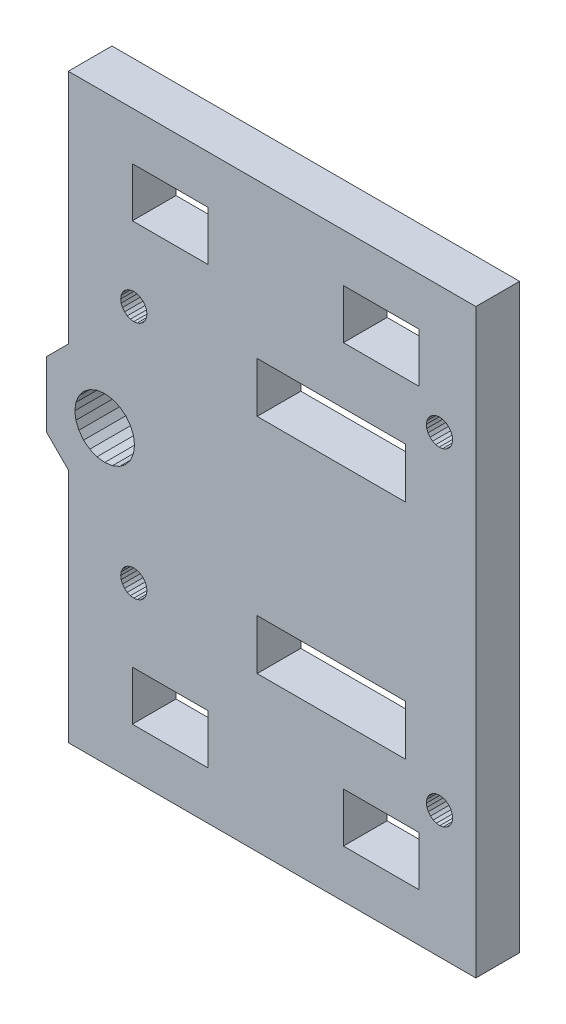
from build123d import *

# Parameters (mm, degrees)
SKETCH1_W           = 20.368459162
SKETCH1_H           = 6.9
SKETCH1_W_2         = 10.4
SKETCH1_H_2         = 6.8
BOSS_EXTRUDE1_DEPTH = 6


with BuildPart() as part:
    # Sketch1 → Boss-Extrude1 (new body)
    with BuildSketch(Plane.XY):
        Polygon((-451.41165464, -88.013150874), (-507.41165464, -88.013150874), (-507.41165464, -120.474064779), (-510.41165464, -123.474064779), (-510.41165464, -132.452236968), (-507.41165464, -135.452236968), (-507.41165464, -167.913150874), (-451.41165464, -167.913150874), align=None)
        with Locations((-471.27842313, -143.263150874)):
            Rectangle(SKETCH1_W, SKETCH1_H, mode=Mode.SUBTRACT)
        Polygon((-498.31165464, -127.963150874), (-498.451358752, -126.901992789), (-498.860950485, -125.913150874), (-499.512516837, -125.064013071), (-500.36165464, -124.412446718), (-501.350496555, -124.002854986), (-502.41165464, -123.863150874), (-503.472812725, -124.002854986), (-504.46165464, -124.412446718), (-505.310792443, -125.064013071), (-505.962358796, -125.913150874), (-506.371950528, -126.901992789), (-506.51165464, -127.963150874), (-506.371950528, -129.024308959), (-505.962358796, -130.013150874), (-505.310792443, -130.862288677), (-504.46165464, -131.513855029), (-503.472812725, -131.923446762), (-502.41165464, -132.063150874), (-501.350496555, -131.923446762), (-500.36165464, -131.513855029), (-499.512516837, -130.862288677), (-498.860950485, -130.013150874), (-498.451358752, -129.024308959), align=None, mode=Mode.SUBTRACT)
        Polygon((-499.970500367, -110.613150874), (-500.150321127, -111.047276593), (-500.21165464, -111.513150874), (-500.150321127, -111.979025155), (-499.970500367, -112.413150874), (-499.684446846, -112.78594308), (-499.31165464, -113.071996601), (-498.877528921, -113.251817361), (-498.41165464, -113.313150874), (-497.945780359, -113.251817361), (-497.51165464, -113.071996601), (-497.138862434, -112.78594308), (-496.852808913, -112.413150874), (-496.672988153, -111.979025155), (-496.61165464, -111.513150874), (-496.672988153, -111.047276593), (-496.852808913, -110.613150874), (-497.138862434, -110.240358668), (-497.51165464, -109.954305147), (-497.945780359, -109.774484386), (-498.41165464, -109.713150874), (-498.877528921, -109.774484386), (-499.31165464, -109.954305147), (-499.684446846, -110.240358668), align=None, mode=Mode.SUBTRACT)
        Polygon((-458.160214968, -105.890394107), (-457.990055534, -106.328396861), (-457.712330687, -106.707434531), (-457.345966918, -107.001676326), (-456.91593131, -107.191070154), (-456.451530081, -107.262709139), (-455.984411407, -107.211711202), (-455.546408653, -107.041551767), (-455.167370983, -106.763826921), (-454.873129188, -106.397463151), (-454.68373536, -105.967427544), (-454.612096375, -105.503026315), (-454.663094312, -105.035907641), (-454.833253746, -104.597904886), (-455.110978593, -104.218867216), (-455.477342363, -103.924625421), (-455.90737797, -103.735231593), (-456.371779199, -103.663592609), (-456.838897873, -103.714590546), (-457.276900628, -103.88474998), (-457.655938298, -104.162474827), (-457.950180093, -104.528838596), (-458.139573921, -104.958874204), (-458.211212905, -105.423275433), align=None, mode=Mode.SUBTRACT)
        with Locations((-493.41165464, -157.913150874)):
            Rectangle(SKETCH1_W_2, SKETCH1_H_2, mode=Mode.SUBTRACT)
        with Locations((-493.41165464, -98.013150874)):
            Rectangle(SKETCH1_W_2, SKETCH1_H_2, mode=Mode.SUBTRACT)
        with Locations((-471.27842313, -112.663150874)):
            Rectangle(SKETCH1_W, SKETCH1_H, mode=Mode.SUBTRACT)
        Polygon((-455.546408653, -148.88474998), (-455.984411407, -148.714590546), (-456.451530081, -148.663592609), (-456.91593131, -148.735231593), (-457.345966918, -148.924625421), (-457.712330687, -149.218867216), (-457.990055534, -149.597904886), (-458.160214968, -150.035907641), (-458.211212905, -150.503026315), (-458.139573921, -150.967427544), (-457.950180093, -151.397463151), (-457.655938298, -151.763826921), (-457.276900628, -152.041551767), (-456.838897873, -152.211711202), (-456.371779199, -152.262709139), (-455.90737797, -152.191070154), (-455.477342363, -152.001676326), (-455.110978593, -151.707434531), (-454.833253746, -151.328396861), (-454.663094312, -150.890394107), (-454.612096375, -150.423275433), (-454.68373536, -149.958874204), (-454.873129188, -149.528838596), (-455.167370983, -149.162474827), align=None, mode=Mode.SUBTRACT)
        with Locations((-464.41165464, -157.913150874)):
            Rectangle(SKETCH1_W_2, SKETCH1_H_2, mode=Mode.SUBTRACT)
        with Locations((-464.41165464, -98.013150874)):
            Rectangle(SKETCH1_W_2, SKETCH1_H_2, mode=Mode.SUBTRACT)
        Polygon((-499.970500367, -143.513150874), (-500.150321127, -143.947276593), (-500.21165464, -144.413150874), (-500.150321127, -144.879025155), (-499.970500367, -145.313150874), (-499.684446846, -145.68594308), (-499.31165464, -145.971996601), (-498.877528921, -146.151817361), (-498.41165464, -146.213150874), (-497.945780359, -146.151817361), (-497.51165464, -145.971996601), (-497.138862434, -145.68594308), (-496.852808913, -145.313150874), (-496.672988153, -144.879025155), (-496.61165464, -144.413150874), (-496.672988153, -143.947276593), (-496.852808913, -143.513150874), (-497.138862434, -143.140358668), (-497.51165464, -142.854305147), (-497.945780359, -142.674484386), (-498.41165464, -142.613150874), (-498.877528921, -142.674484386), (-499.31165464, -142.854305147), (-499.684446846, -143.140358668), align=None, mode=Mode.SUBTRACT)
    extrude(amount=BOSS_EXTRUDE1_DEPTH)


solid = part.part
